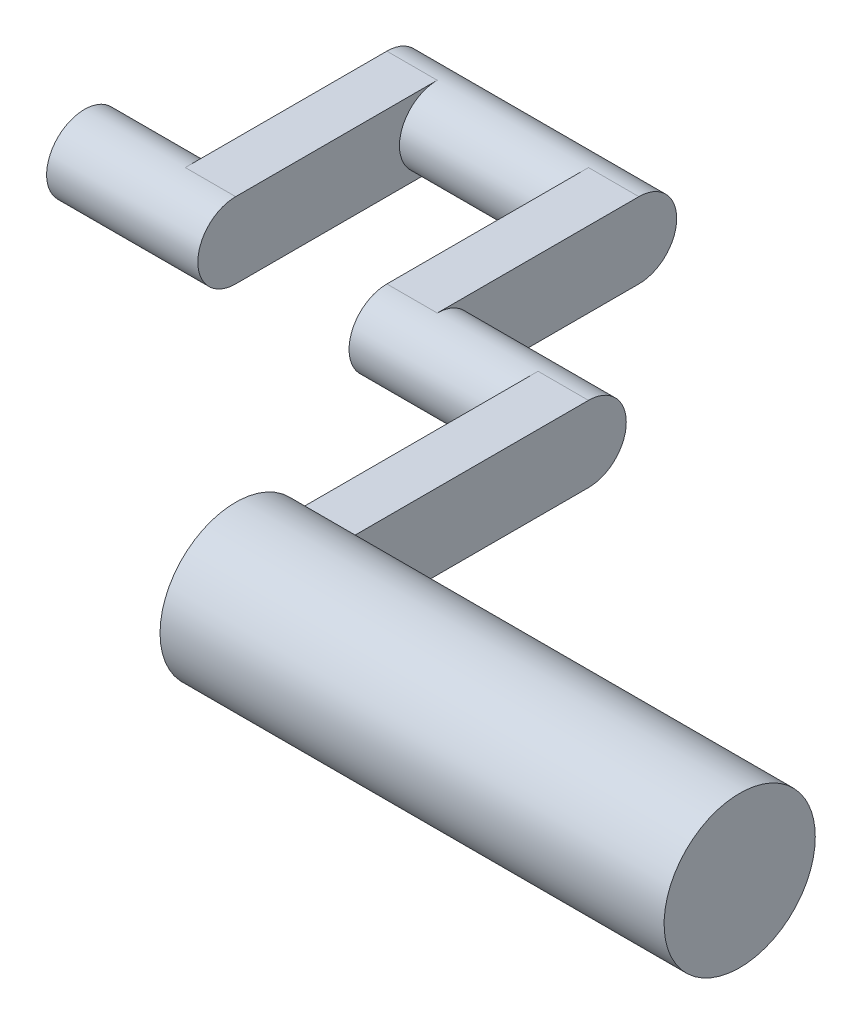
from build123d import *

# Parameters (mm, degrees)
BOSS_EXTRUDE1_DEPTH      = 127
BOSS_EXTRUDE2_DEPTH      = 12.7
BOSS_EXTRUDE3_DEPTH      = 12.7
BOSS_EXTRUDE3_DEPTH_BACK = 38.1
BOSS_EXTRUDE4_START      = -38.1
BOSS_EXTRUDE4_DEPTH      = 12.7
BOSS_EXTRUDE5_START      = -88.9
BOSS_EXTRUDE5_DEPTH      = 63.5
BOSS_EXTRUDE6_START      = -88.9
BOSS_EXTRUDE6_DEPTH      = 12.7
BOSS_EXTRUDE7_START      = -114.3
SKETCH1_8_R              = 9.525
BOSS_EXTRUDE7_DEPTH      = 38.1


with BuildPart() as part:
    # Sketch1 → Boss-Extrude1 (new body)
    with BuildSketch(Plane(origin=(0, 0, 0), x_dir=(0, 0, -1), z_dir=(1, 0, 0))):
        with BuildLine():
            ThreePointArc((19.05, 0), (18.400886991, 4.930502809), (16.497783942, 9.525))
            ThreePointArc((16.497783942, 9.525), (-19.05, 0), (16.497783942, -9.525))
            ThreePointArc((16.497783942, -9.525), (18.400886991, -4.930502809), (19.05, 0))
        make_face()
    extrude(amount=BOSS_EXTRUDE1_DEPTH)

    # Sketch1_3 → Boss-Extrude2 (add)
    with BuildSketch(Plane(origin=(0, 0, 0), x_dir=(0, 0, -1), z_dir=(1, 0, 0))):
        with BuildLine():
            ThreePointArc((76.2, -9.525), (66.675, 0), (76.2, 9.525))
            Line((76.2, 9.525), (16.497783942, 9.525))
            ThreePointArc((16.497783942, 9.525), (18.400886991, 4.930502809), (19.05, 0))
            ThreePointArc((19.05, 0), (18.400886991, -4.930502809), (16.497783942, -9.525))
            Line((16.497783942, -9.525), (76.2, -9.525))
        make_face()
    extrude(amount=BOSS_EXTRUDE2_DEPTH)

    # Sketch1_4 → Boss-Extrude3 (add, two sides: drawn at the far end of the back side and taken through both)
    with BuildSketch(Plane(origin=(0, 0, 0), x_dir=(0, 0, -1), z_dir=(1, 0, 0)).offset(-BOSS_EXTRUDE3_DEPTH_BACK)):
        with BuildLine():
            ThreePointArc((85.725, 0), (82.935192091, 6.735192091), (76.2, 9.525))
            ThreePointArc((76.2, 9.525), (66.675, 0), (76.2, -9.525))
            ThreePointArc((76.2, -9.525), (82.935192091, -6.735192091), (85.725, 0))
        make_face()
    extrude(amount=BOSS_EXTRUDE3_DEPTH + BOSS_EXTRUDE3_DEPTH_BACK)

    # Sketch1_5 → Boss-Extrude4 (add)
    with BuildSketch(Plane(origin=(0, 0, 0), x_dir=(0, 0, -1), z_dir=(1, 0, 0)).offset(BOSS_EXTRUDE4_START)):
        with BuildLine():
            ThreePointArc((127, -9.525), (117.475, 0), (127, 9.525))
            Line((127, 9.525), (76.2, 9.525))
            ThreePointArc((76.2, 9.525), (82.935192091, 6.735192091), (85.725, 0))
            ThreePointArc((85.725, 0), (82.935192091, -6.735192091), (76.2, -9.525))
            Line((76.2, -9.525), (127, -9.525))
        make_face()
    extrude(amount=BOSS_EXTRUDE4_DEPTH)

    # Sketch1_6 → Boss-Extrude5 (add)
    with BuildSketch(Plane(origin=(0, 0, 0), x_dir=(0, 0, -1), z_dir=(1, 0, 0)).offset(BOSS_EXTRUDE5_START)):
        with BuildLine():
            ThreePointArc((136.525, 0), (133.735192091, 6.735192091), (127, 9.525))
            ThreePointArc((127, 9.525), (117.475, 0), (127, -9.525))
            ThreePointArc((127, -9.525), (133.735192091, -6.735192091), (136.525, 0))
        make_face()
    extrude(amount=BOSS_EXTRUDE5_DEPTH)

    # Sketch1_7 → Boss-Extrude6 (add)
    with BuildSketch(Plane(origin=(0, 0, 0), x_dir=(0, 0, -1), z_dir=(1, 0, 0)).offset(BOSS_EXTRUDE6_START)):
        with BuildLine():
            ThreePointArc((127, -9.525), (117.475, 0), (127, 9.525))
            Line((127, 9.525), (76.2, 9.525))
            ThreePointArc((76.2, 9.525), (82.935192091, 6.735192091), (85.725, 0))
            ThreePointArc((85.725, 0), (82.935192091, -6.735192091), (76.2, -9.525))
            Line((76.2, -9.525), (127, -9.525))
        make_face()
    extrude(amount=BOSS_EXTRUDE6_DEPTH)

    # Sketch1_8 → Boss-Extrude7 (add)
    with BuildSketch(Plane(origin=(0, 0, 0), x_dir=(0, 0, -1), z_dir=(1, 0, 0)).offset(BOSS_EXTRUDE7_START)):
        with Locations((76.2, 0)):
            Circle(SKETCH1_8_R)
    extrude(amount=BOSS_EXTRUDE7_DEPTH)


solid = part.part
